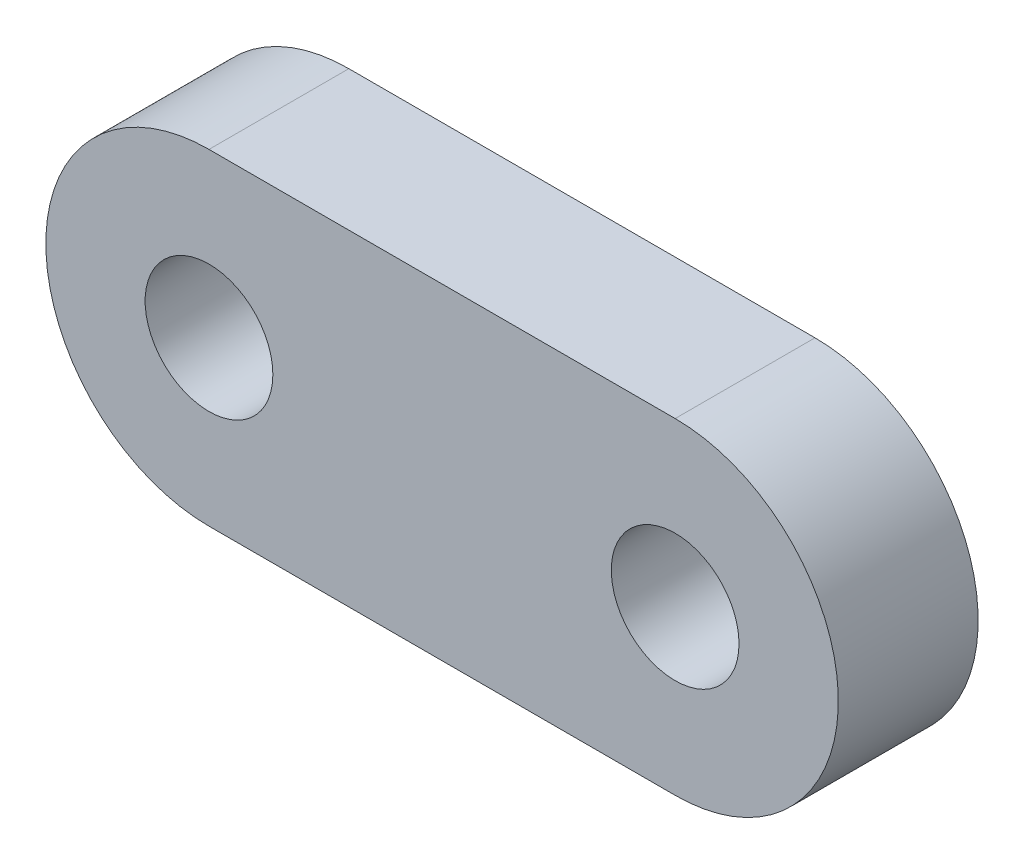
from build123d import *

# Parameters (mm, degrees)
BOSS_EXTRUDE1_DEPTH = 3.81
CUT_EXTRUDE1_START  = -4.81
SKETCH2_R           = 1.7399
CUT_EXTRUDE1_DEPTH  = 5.81


with BuildPart() as part:
    # Sketch1 → Boss-Extrude1 (new body)
    with BuildSketch(Plane.XY):
        with BuildLine():
            Line((0, 4.445), (12.7, 4.445))
            ThreePointArc((12.7, 4.445), (17.145, 0), (12.7, -4.445))
            Line((12.7, -4.445), (0, -4.445))
            ThreePointArc((0, -4.445), (-4.445, 0), (0, 4.445))
        make_face()
    extrude(amount=BOSS_EXTRUDE1_DEPTH)

    # Sketch2 → Cut-Extrude1 (cut)
    with BuildSketch(Plane.XY.offset(3.81).offset(CUT_EXTRUDE1_START)):
        Circle(SKETCH2_R)
    cut_extrude1 = extrude(amount=CUT_EXTRUDE1_DEPTH, mode=Mode.SUBTRACT)

    # Mirror1: Cut-Extrude1 across plane
    add(cut_extrude1.mirror(Plane(origin=(6.35, 0, 0), x_dir=(0, 0, 1), z_dir=(1, 0, 0))), mode=Mode.SUBTRACT)


solid = part.part
